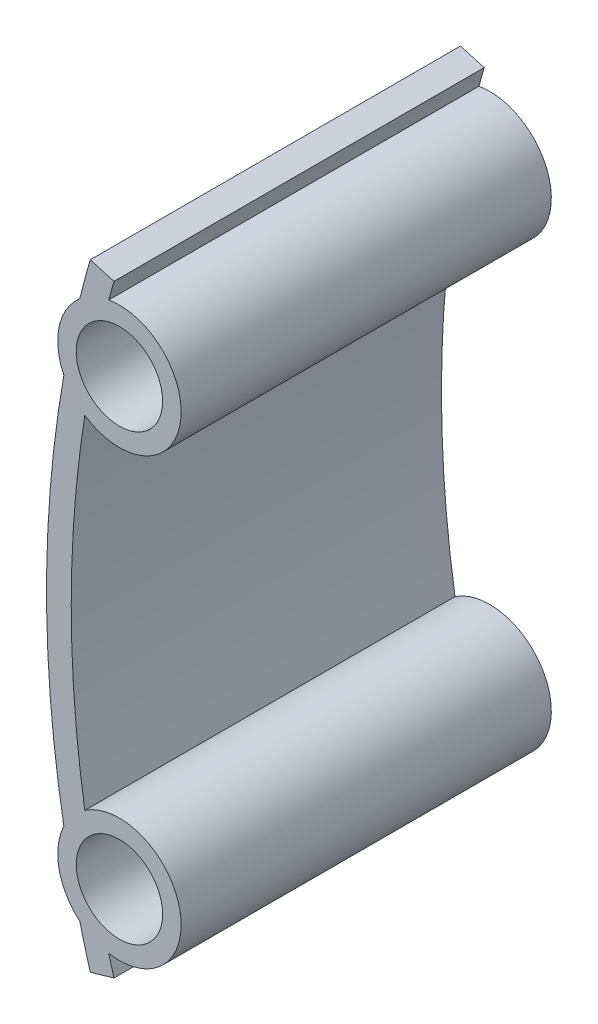
from build123d import *

# Parameters (mm, degrees)
SKETCH1_R           = 3.5
BOSS_EXTRUDE1_DEPTH = 30


with BuildPart() as part:
    # Sketch1 → Boss-Extrude1 (new body)
    with BuildSketch(Plane.XY):
        with BuildLine():
            Line((3.541917671, 25), (5.463208389, 24.444444444))
            ThreePointArc((5.463208389, 24.444444444), (5.24739546, 23.685354625), (5.038398555, 22.924359969))
            ThreePointArc((5.038398555, 22.924359969), (10.794070727, 16.953488372), (3.098606761, 13.861740626))
            ThreePointArc((3.098606761, 13.861740626), (2, 0), (3.098606761, -13.861740626))
            ThreePointArc((3.098606761, -13.861740626), (10.794070727, -16.953488372), (5.038398555, -22.924359969))
            ThreePointArc((5.038398555, -22.924359969), (5.24739546, -23.685354625), (5.463208389, -24.444444444))
            Line((5.463208389, -24.444444444), (3.541917671, -25))
            ThreePointArc((3.541917671, -25), (3.099888289, -23.417313778), (2.686828675, -21.826820958))
            ThreePointArc((2.686828675, -21.826820958), (1.01556094, -19.046511628), (1.402328405, -15.825693915))
            ThreePointArc((1.402328405, -15.825693915), (0, 0), (1.402328405, 15.825693915))
            ThreePointArc((1.402328405, 15.825693915), (1.01556094, 19.046511628), (2.686828675, 21.826820958))
            ThreePointArc((2.686828675, 21.826820958), (3.099888289, 23.417313778), (3.541917671, 25))
        make_face()
        with Locations((5.904815833, 18)):
            Circle(SKETCH1_R, mode=Mode.SUBTRACT)
        with Locations((5.904815833, -18)):
            Circle(SKETCH1_R, mode=Mode.SUBTRACT)
    extrude(amount=BOSS_EXTRUDE1_DEPTH)


solid = part.part
